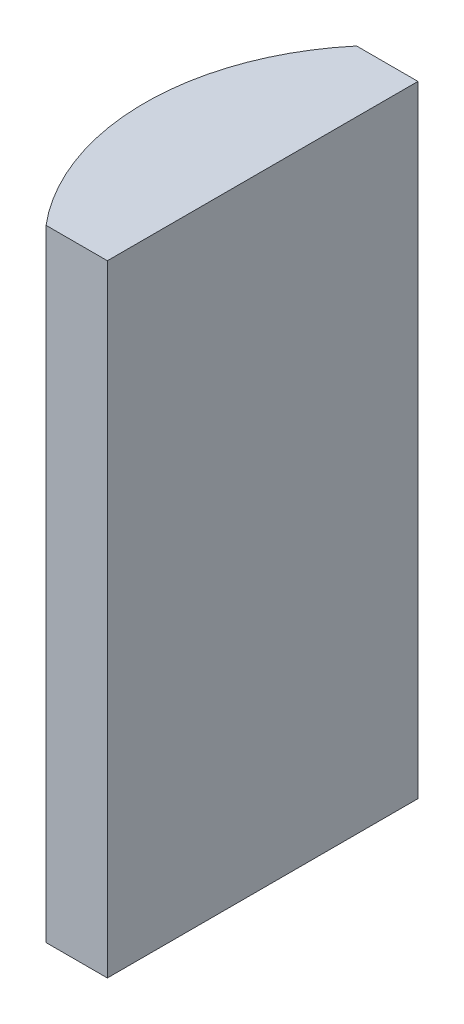
from build123d import *

# Parameters (mm, degrees)
EXTRUDE_1_DEPTH = 20


with BuildPart() as part:
    # 草图1 → 凸台-拉伸1 (new body)
    with BuildSketch(Plane(origin=(0, 0, 0), x_dir=(1, 0, 0), z_dir=(0, 1, 0))):
        with BuildLine():
            Line((-1.579237509, 5), (0.395204335, 5))
            Line((0.395204335, 5), (0.395204335, -5))
            Line((0.395204335, -5), (-1.579237509, -5))
            ThreePointArc((-1.579237509, -5), (-3.404795665, 0), (-1.579237509, 5))
        make_face()
    extrude(amount=EXTRUDE_1_DEPTH)


solid = part.part
